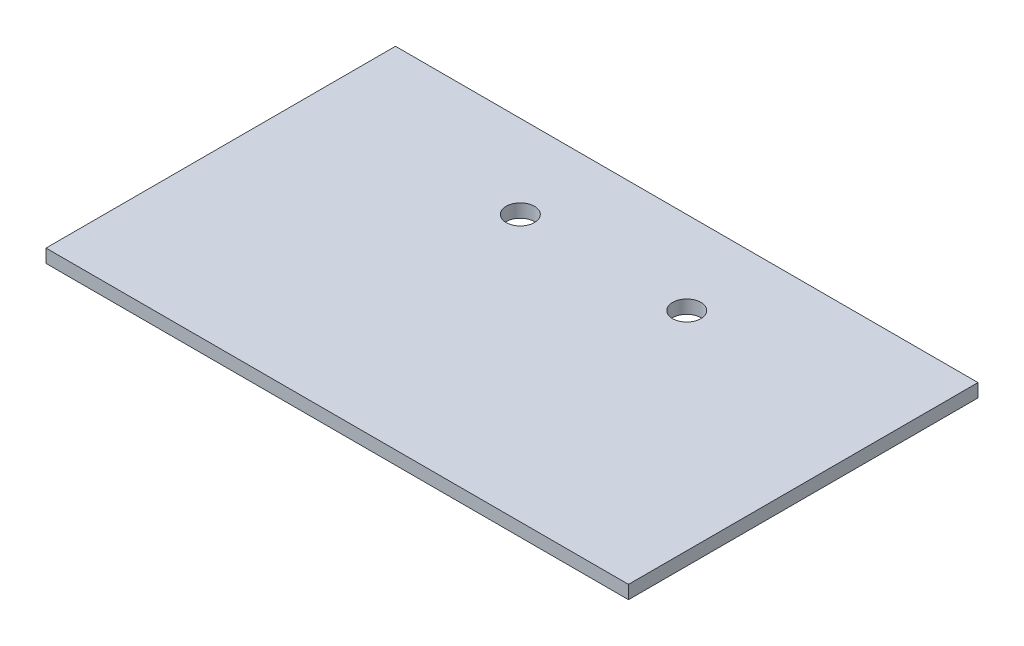
from build123d import *

# Parameters (mm, degrees)
SKETCH1_W            = 70
SKETCH1_H            = 42
BOSS_EXTRUDE1_DEPTH  = 1.6
M3_CLEARANCE_HOLE1_D = 3.4


with BuildPart() as part:
    # Sketch1 → Boss-Extrude1 (new body)
    with BuildSketch(Plane(origin=(0, 0, 0), x_dir=(1, 0, 0), z_dir=(0, 1, 0))):
        Rectangle(SKETCH1_W, SKETCH1_H)
    extrude(amount=BOSS_EXTRUDE1_DEPTH)

    # M3 Clearance Hole1 (through all)
    with Locations(Plane(origin=(0, 1.6, 0), x_dir=(1, 0, 0), z_dir=(0, 1, 0))):
        with Locations((-10, 11)):
            m3_clearance_hole1 = Hole(M3_CLEARANCE_HOLE1_D / 2)

    # Mirror1: M3 Clearance Hole1 across plane
    add(m3_clearance_hole1.mirror(Plane(origin=(0, 0, 0), x_dir=(0, 0, 1), z_dir=(1, 0, 0))), mode=Mode.SUBTRACT)


solid = part.part
